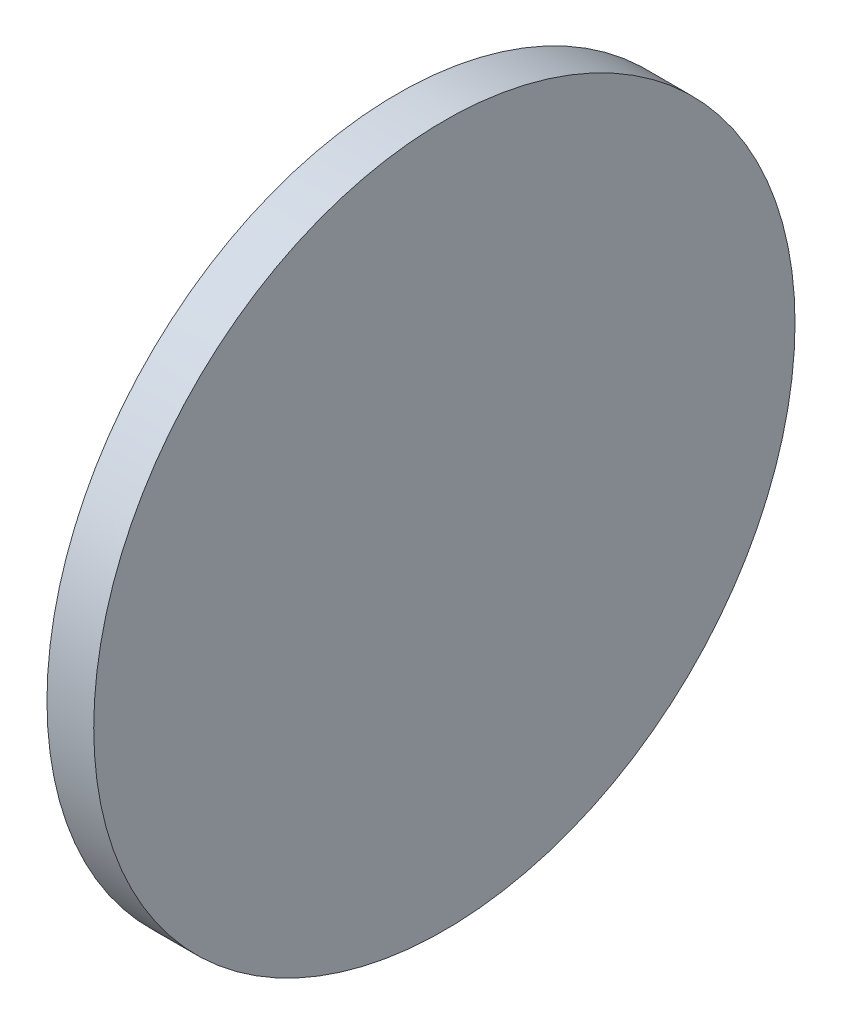
from build123d import *

# Parameters (mm, degrees)
SKETCH_1_W = 2
SKETCH_1_H = 15


with BuildPart() as part:
    # 草图1 → 旋转1 (revolve)
    with BuildSketch(Plane.XY, mode=Mode.PRIVATE) as revolve_1_sk:
        with Locations((261.116303666, 84.793179349)):
            Rectangle(SKETCH_1_W, SKETCH_1_H)
    revolve(revolve_1_sk.sketch.rotate(Axis((254.000801993, 77.293179349, 0), (1, 0, 0)), 90), axis=Axis((254.000801993, 77.293179349, 0), (1, 0, 0)))  # turned: the seam where the file's is


solid = part.part
